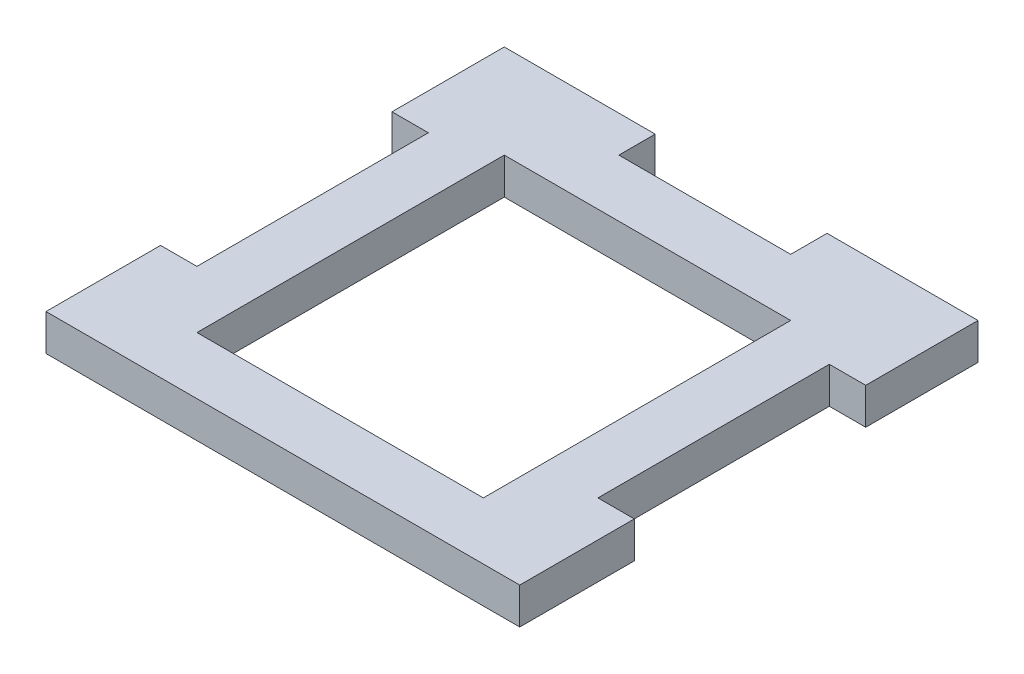
from build123d import *

# Parameters (mm, degrees)
SKETCH1_W           = 41.35
SKETCH1_H           = 40
BOSS_EXTRUDE1_DEPTH = 3.175
SKETCH2_W           = 3.175
SKETCH2_H           = 20.2
SKETCH2_W_2         = 15
SKETCH2_H_2         = 3.175
CUT_EXTRUDE1_DEPTH  = 4.175
SKETCH3_W           = 25
SKETCH3_H           = 26.825
CUT_EXTRUDE2_DEPTH  = 4.175


with BuildPart() as part:
    # Sketch1 → Boss-Extrude1 (new body)
    with BuildSketch(Plane(origin=(0, 0, 0), x_dir=(1, 0, 0), z_dir=(0, 1, 0))):
        with Locations((20.675, 20)):
            Rectangle(SKETCH1_W, SKETCH1_H)
    extrude(amount=BOSS_EXTRUDE1_DEPTH)

    # Sketch2 → Cut-Extrude1 (cut, through all)
    with BuildSketch(Plane.XZ):
        with Locations((39.7625, -20.1)):
            Rectangle(SKETCH2_W, SKETCH2_H)
        with Locations((1.5875, -20.1)):
            Rectangle(SKETCH2_W, SKETCH2_H)
        with Locations((20.675, -38.4125)):
            Rectangle(SKETCH2_W_2, SKETCH2_H_2)
    extrude(amount=-CUT_EXTRUDE1_DEPTH, mode=Mode.SUBTRACT)

    # Sketch3 → Cut-Extrude2 (cut, through all)
    with BuildSketch(Plane(origin=(0, 3.175, 0), x_dir=(1, 0, 0), z_dir=(0, 1, 0))):
        with Locations((20.675, 18.4125)):
            Rectangle(SKETCH3_W, SKETCH3_H)
    extrude(amount=-CUT_EXTRUDE2_DEPTH, mode=Mode.SUBTRACT)


solid = part.part
